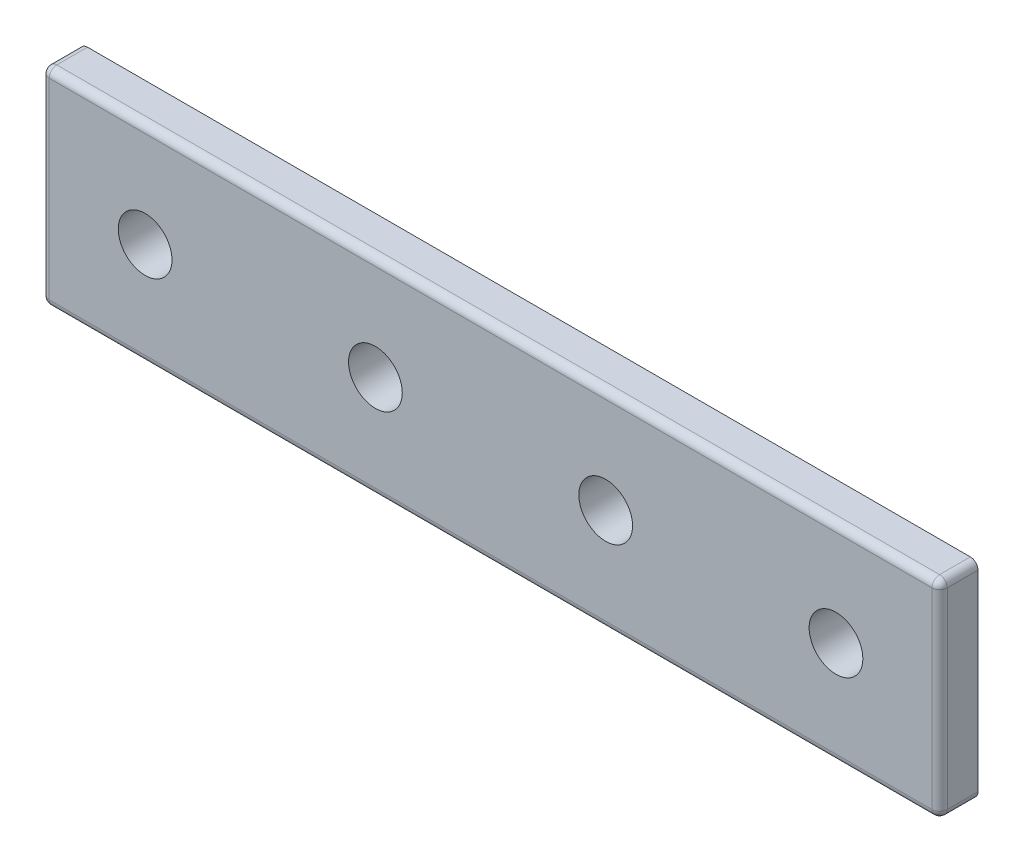
from build123d import *

# Parameters (mm, degrees)
SKETCH1_W           = 117
SKETCH1_H           = 27
SKETCH1_R           = 3.5
BOSS_EXTRUDE1_DEPTH = 2.5
FILLET1_R           = 1


with BuildPart() as part:
    # Sketch1 → Boss-Extrude1 (new body, symmetric)
    with BuildSketch(Plane.XY):
        with Locations((58.5, 13.5)):
            Rectangle(SKETCH1_W, SKETCH1_H)
        with Locations((13.5, 13.5)):
            Circle(SKETCH1_R, mode=Mode.SUBTRACT)
        with Locations((43.5, 13.5)):
            Circle(SKETCH1_R, mode=Mode.SUBTRACT)
        with Locations((73.5, 13.5)):
            Circle(SKETCH1_R, mode=Mode.SUBTRACT)
        with Locations((103.5, 13.5)):
            Circle(SKETCH1_R, mode=Mode.SUBTRACT)
    extrude(amount=BOSS_EXTRUDE1_DEPTH, both=True)

    # Fillet1
    fillet1_edges = [part.edges().sort_by_distance(p)[0] for p in [
        (58.5, 27, 2.5),
        (0, 13.5, 2.5),
        (58.5, 0, 2.5),
        (117, 13.5, 2.5),
        (0, 0, 0),
        (0, 27, 0),
        (117, 27, 0),
        (117, 0, 0),
    ]]
    fillet(fillet1_edges, radius=FILLET1_R)


solid = part.part
